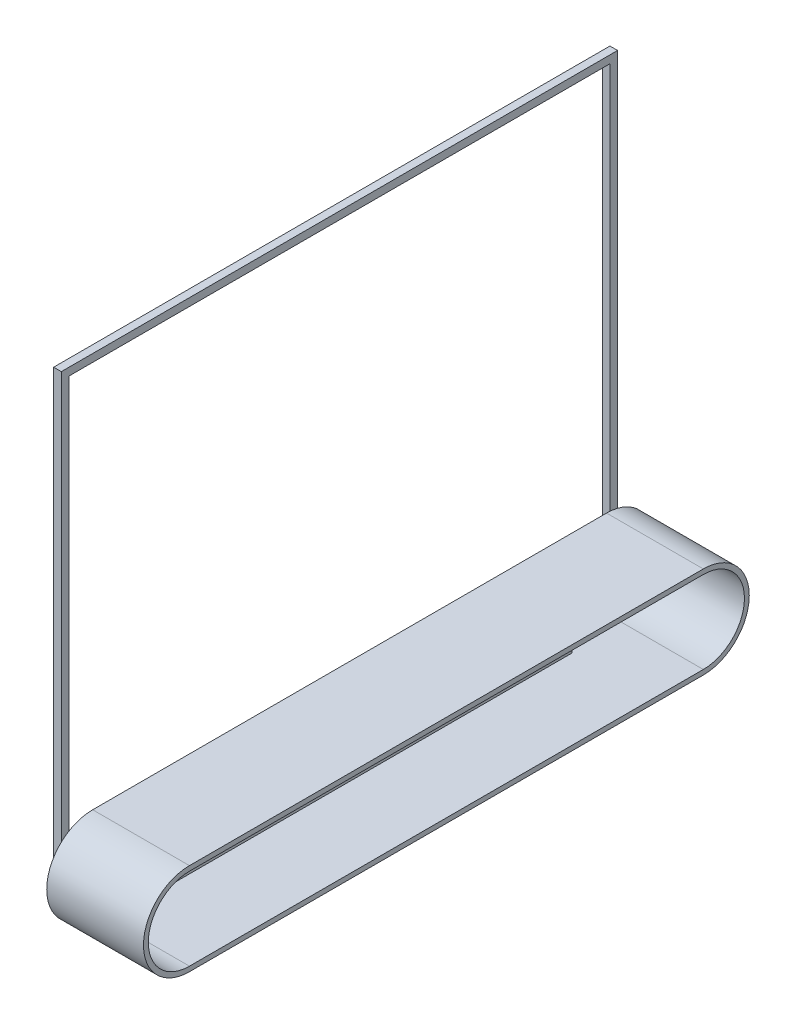
from build123d import *

# Parameters (mm, degrees)
SKETCH1_W           = 1118.25
SKETCH1_H           = 944.035
BOSS_EXTRUDE1_DEPTH = 15.875
SKETCH2_W           = 15.875
SKETCH2_H           = 15.875
BOSS_EXTRUDE2_DEPTH = 55.785
SKETCH3_W           = 15.875
SKETCH3_H           = 15.875
BOSS_EXTRUDE3_DEPTH = 850
EXTRUDE_THIN2_START = 21
SKETCH4_W           = 850
SKETCH4_H           = 10
EXTRUDE_THIN2_DEPTH = 200
SKETCH5_W           = 15.875
SKETCH5_H           = 100
BOSS_EXTRUDE4_DEPTH = 120
SKETCH7_W           = 54
SKETCH7_H           = 100
SKETCH7_R           = 15
BOSS_EXTRUDE5_DEPTH = 20
BOSS_EXTRUDE6_DEPTH = 15.875
SKETCH11_W          = 100
SKETCH11_H          = 68.25
CUT_EXTRUDE1_DEPTH  = 20


with BuildPart() as part:
    # Sketch1 → Boss-Extrude1 (new body)
    with BuildSketch(Plane(origin=(0, 0, 0), x_dir=(0, 0, -1), z_dir=(1, 0, 0))):
        Polygon((-575, -487.8925), (-575, 487.8925), (575, 487.8925), (575, -487.8925), (559.125, -487.8925), (-559.125, -487.8925), align=None)
        Rectangle(SKETCH1_W, SKETCH1_H, mode=Mode.SUBTRACT)
    extrude(amount=BOSS_EXTRUDE1_DEPTH)

    # Sketch2 → Boss-Extrude2 (add)
    with BuildSketch(Plane(origin=(15.875, 0, 0), x_dir=(0, 0, -1), z_dir=(1, 0, 0))):
        with Locations((-417.0625, -479.955)):
            Rectangle(SKETCH2_W, SKETCH2_H)
        with Locations((417.0625, -479.955)):
            Rectangle(SKETCH2_W, SKETCH2_H)
    extrude(amount=BOSS_EXTRUDE2_DEPTH)

    # Sketch3 → Boss-Extrude3 (add)
    with BuildSketch(Plane.XY.offset(425)):
        with Locations((63.8125, -479.955)):
            Rectangle(SKETCH3_W, SKETCH3_H)
    extrude(amount=-BOSS_EXTRUDE3_DEPTH)

    # Sketch4 → Extrude-Thin2 (add)
    with BuildSketch(Plane(origin=(15.875, 0, 0), x_dir=(0, 0, -1), z_dir=(1, 0, 0)).offset(EXTRUDE_THIN2_START)):
        with Locations((0, -492.8925)):
            Rectangle(SKETCH4_W, SKETCH4_H)
        with BuildLine():
            Line((531.125, -497.8925), (-531.125, -497.8925))
            ThreePointArc((-531.125, -497.8925), (-626.125, -402.8925), (-531.125, -307.8925))
            Line((-531.125, -307.8925), (531.125, -307.8925))
            ThreePointArc((531.125, -307.8925), (626.125, -402.8925), (531.125, -497.8925))
        make_face()
        with BuildLine():
            Line((531.125, -487.8925), (-531.125, -487.8925))
            ThreePointArc((-531.125, -487.8925), (-616.125, -402.8925), (-531.125, -317.8925))
            Line((-531.125, -317.8925), (531.125, -317.8925))
            ThreePointArc((531.125, -317.8925), (616.125, -402.8925), (531.125, -487.8925))
        make_face(mode=Mode.SUBTRACT)
    extrude(amount=EXTRUDE_THIN2_DEPTH)

    # Sketch5 → Boss-Extrude4 (add)
    with BuildSketch(Plane(origin=(15.875, 0, 0), x_dir=(0, 0, -1), z_dir=(1, 0, 0))):
        with Locations((-567.0625, -402.8925)):
            Rectangle(SKETCH5_W, SKETCH5_H)
    extrude(amount=BOSS_EXTRUDE4_DEPTH)

    # Sketch7 → Boss-Extrude5 (add)
    with BuildSketch(Plane(origin=(135.875, 0, 0), x_dir=(0, 0, -1), z_dir=(1, 0, 0))):
        with Locations((-532.125, -402.8925)):
            Rectangle(SKETCH7_W, SKETCH7_H)
        with Locations((-531.125, -402.8925)):
            Circle(SKETCH7_R, mode=Mode.SUBTRACT)
    extrude(amount=-BOSS_EXTRUDE5_DEPTH)

    # Sketch9 → Boss-Extrude6 (add)
    with BuildSketch(Plane(origin=(71.75, 0, 0), x_dir=(0, 0, -1), z_dir=(1, 0, 0))):
        Polygon((-425, -472.0175), (-312.541363962, -472.0175), (-559.125, -436.856925616), (-559.125, -452.8925), align=None)
    extrude(amount=-BOSS_EXTRUDE6_DEPTH)

    # Sketch11 → Cut-Extrude1 (cut)
    with BuildSketch(Plane(origin=(0, 0, 559.125), x_dir=(-1, 0, 0), z_dir=(0, 0, -1))):
        with Locations((-65.875, -402.8925)):
            Rectangle(SKETCH11_W, SKETCH11_H)
    extrude(amount=-CUT_EXTRUDE1_DEPTH, mode=Mode.SUBTRACT)


solid = part.part
